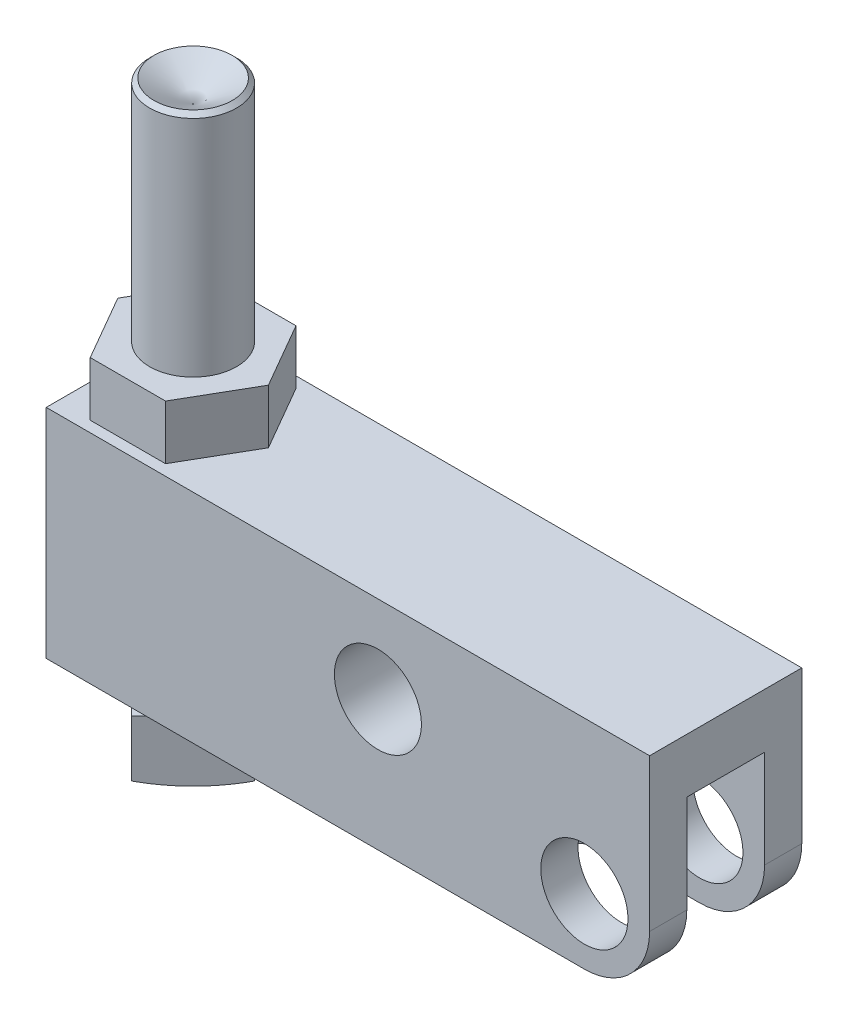
from build123d import *

# Parameters (mm, degrees)
SKETCH11_W         = 88.1126
SKETCH11_H         = 31.75
SKETCH11_R         = 6.36905
SKETCH11_R_2       = 6.35635
EXTRUDE3_DEPTH     = 11.1125
CUT_EXTRUDE1_DEPTH = 23.7998
FILLET1_R          = 9.525
EXTRUDE4_DEPTH     = 7.9248
SKETCH15_R         = 21.901149079
CUT_EXTRUDE2_DEPTH = 10.525


with BuildPart() as part:
    # Sketch11 → Extrude3 (new body, symmetric)
    with BuildSketch(Plane.XY):
        with Locations((-34.5313, 6.35)):
            Rectangle(SKETCH11_W, SKETCH11_H)
        Circle(SKETCH11_R, mode=Mode.SUBTRACT)
        with Locations((-30.1498, 9.525)):
            Circle(SKETCH11_R_2, mode=Mode.SUBTRACT)
    extrude(amount=EXTRUDE3_DEPTH, both=True)

    # Sketch12 → Cut-Extrude1 (cut)
    with BuildSketch(Plane.XZ.offset(9.525)):
        with BuildLine():
            Line((-12.7127, 5.6769), (9.525, 5.6769))
            Line((9.525, 5.6769), (9.525, -5.6769))
            Line((9.525, -5.6769), (-12.7127, -5.6769))
            ThreePointArc((-12.7127, -5.6769), (-18.3896, 0), (-12.7127, 5.6769))
        make_face()
    extrude(amount=-CUT_EXTRUDE1_DEPTH, mode=Mode.SUBTRACT)

    # Fillet1
    fillet1_edges = [part.edges().sort_by_distance(p)[0] for p in [
        (9.525, -9.525, -8.3947),
        (9.525, -9.525, 8.3947),
    ]]
    fillet(fillet1_edges, radius=FILLET1_R)

    # Sketch13 → Extrude4 (add)
    with BuildSketch(Plane(origin=(0, 22.225, 0), x_dir=(1, 0, 0), z_dir=(0, 1, 0))):
        Polygon((-57.251277372, 0), (-62.750538686, 9.525), (-73.749061314, 9.525), (-79.248322628, 0), (-73.749061314, -9.525), (-62.750538686, -9.525), align=None)
    extrude(amount=EXTRUDE4_DEPTH)

    # Sketch14 → Revolve2 (revolve)
    with BuildSketch(Plane.XY, mode=Mode.PRIVATE) as revolve2_sk:
        with BuildLine():
            Line((-68.2498, 60.200443212), (-73.9648, 63.5))
            Line((-73.9648, 63.5), (-74.5998, 62.865))
            Line((-74.5998, 62.865), (-74.5998, -12.7))
            Line((-74.5998, -12.7), (-90.150949079, -12.7))
            Line((-90.150949079, -12.7), (-90.150949079, -13.462))
            ThreePointArc((-90.150949079, -13.462), (-80.044401519, -19.952955747), (-68.2498, -22.225))
            Line((-68.2498, -22.225), (-68.2498, 60.200443212))
        make_face()
    revolve(revolve2_sk.sketch.rotate(Axis((-68.2498, 26.585218564, 0), (0, -1, 0)), 270), axis=Axis((-68.2498, 26.585218564, 0), (0, -1, 0)))  # turned: the seam where the file's is

    # Sketch15 → Cut-Extrude2 (cut, through all)
    with BuildSketch(Plane(origin=(0, -12.7, 0), x_dir=(1, 0, 0), z_dir=(0, 1, 0))):
        with Locations((-68.2498, 0)):
            Circle(SKETCH15_R)
        Polygon((-68.2498, 8.980256121), (-77.230056121, 0), (-68.2498, -8.980256121), (-59.269543879, 0), align=None, mode=Mode.SUBTRACT)
    extrude(amount=-CUT_EXTRUDE2_DEPTH, mode=Mode.SUBTRACT)


solid = part.part
